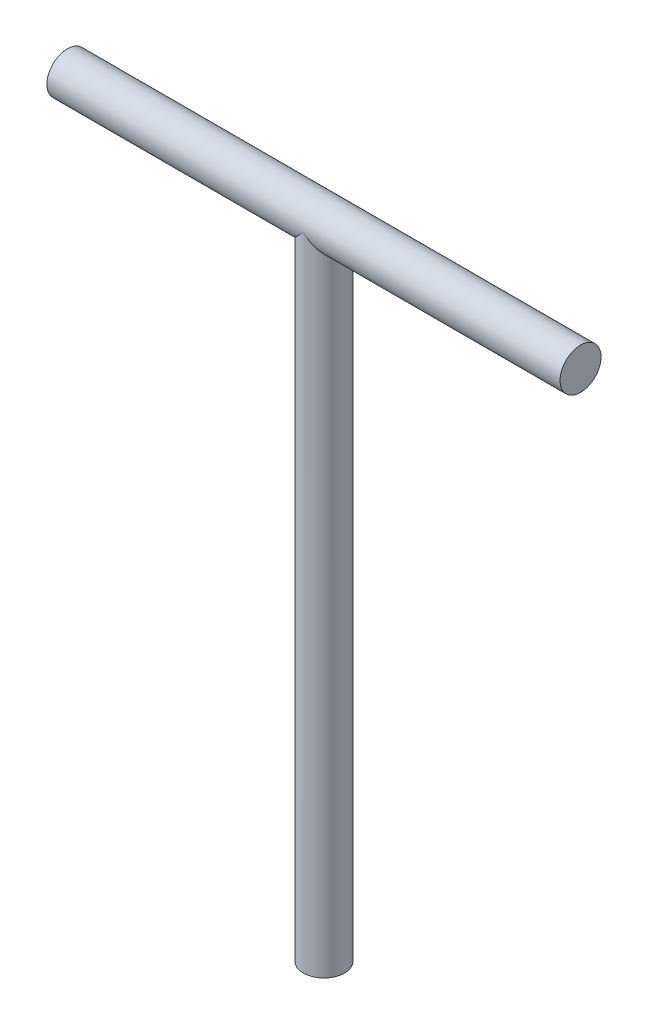
from build123d import *

# Parameters (mm, degrees)
SKETCH1_R           = 16
BOSS_EXTRUDE1_DEPTH = 400
SKETCH2_R           = 16
BOSS_EXTRUDE2_DEPTH = 500


with BuildPart() as part:
    # Sketch1 → Boss-Extrude1 (new body)
    with BuildSketch(Plane(origin=(0, 0, 0), x_dir=(0, 0, -1), z_dir=(1, 0, 0))):
        Circle(SKETCH1_R)
    extrude(amount=BOSS_EXTRUDE1_DEPTH)

    # Sketch2 → Boss-Extrude2 (add)
    with BuildSketch(Plane(origin=(0, 0, 0), x_dir=(1, 0, 0), z_dir=(0, 1, 0))):
        with Locations((200, 0)):
            Circle(SKETCH2_R)
    extrude(amount=-BOSS_EXTRUDE2_DEPTH)


solid = part.part
